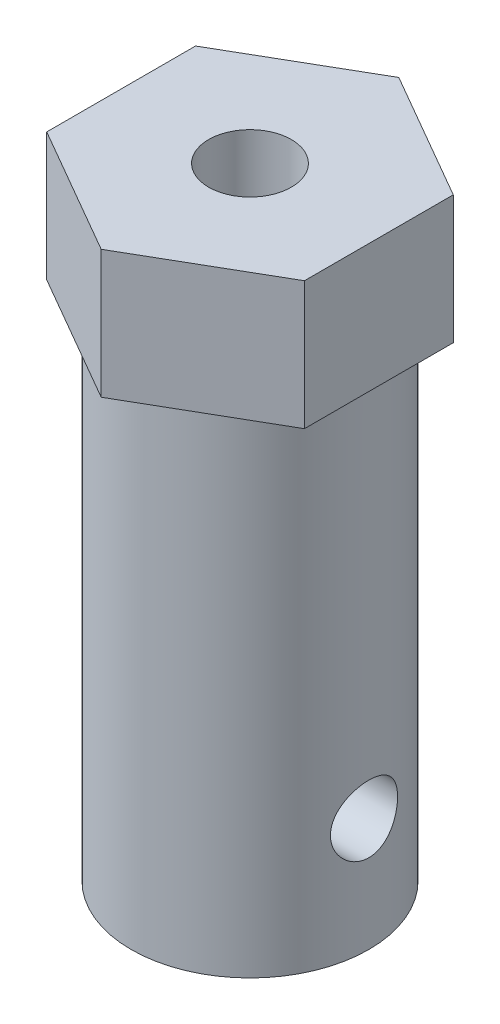
from build123d import *

# Parameters (mm, degrees)
SKETCH1_R               = 5.75
CYLINDERBASE_DEPTH      = 30.07
SKETCH2_R               = 3.34
THROUGHHOLE_DEPTH       = 31.07
BOSS_EXTRUDE2_DEPTH     = 6.2
SKETCH4_R               = 2
CUT_EXTRUDE2_DEPTH      = 31.07
SKETCH5_R               = 1.625
CUT_EXTRUDE3_DEPTH      = 7.235382907
CUT_EXTRUDE3_DEPTH_BACK = 7.235382907


with BuildPart() as part:
    # Sketch1 → cylinderBase (new body)
    with BuildSketch(Plane(origin=(0, 0, 0), x_dir=(1, 0, 0), z_dir=(0, 1, 0))):
        Circle(SKETCH1_R)
    extrude(amount=CYLINDERBASE_DEPTH)

    # Sketch2 → throughHole (cut, through all)
    with BuildSketch(Plane(origin=(0, 30.07, 0), x_dir=(1, 0, 0), z_dir=(0, 1, 0))):
        Circle(SKETCH2_R)
    extrude(amount=-THROUGHHOLE_DEPTH, mode=Mode.SUBTRACT)

    # Sketch3 → Boss-Extrude2 (add)
    with BuildSketch(Plane(origin=(0, 30.07, 0), x_dir=(1, 0, 0), z_dir=(0, 1, 0))):
        Polygon((0, -7.2), (6.235382907, -3.6), (6.235382907, 3.6), (0, 7.2), (-6.235382907, 3.6), (-6.235382907, -3.6), align=None)
    extrude(amount=-BOSS_EXTRUDE2_DEPTH)

    # Sketch4 → Cut-Extrude2 (cut, through all)
    with BuildSketch(Plane(origin=(0, 30.07, 0), x_dir=(1, 0, 0), z_dir=(0, 1, 0))):
        Circle(SKETCH4_R)
    extrude(amount=-CUT_EXTRUDE2_DEPTH, mode=Mode.SUBTRACT)

    # Sketch5 → Cut-Extrude3 (cut, two sides)
    with BuildSketch(Plane(origin=(0, 0, 0), x_dir=(0, 0, -1), z_dir=(1, 0, 0))) as cut_extrude3_sk:
        with Locations((0, 5.475)):
            Circle(SKETCH5_R)
    extrude(amount=CUT_EXTRUDE3_DEPTH, mode=Mode.SUBTRACT)
    extrude(cut_extrude3_sk.sketch, amount=-CUT_EXTRUDE3_DEPTH_BACK, mode=Mode.SUBTRACT)


solid = part.part
